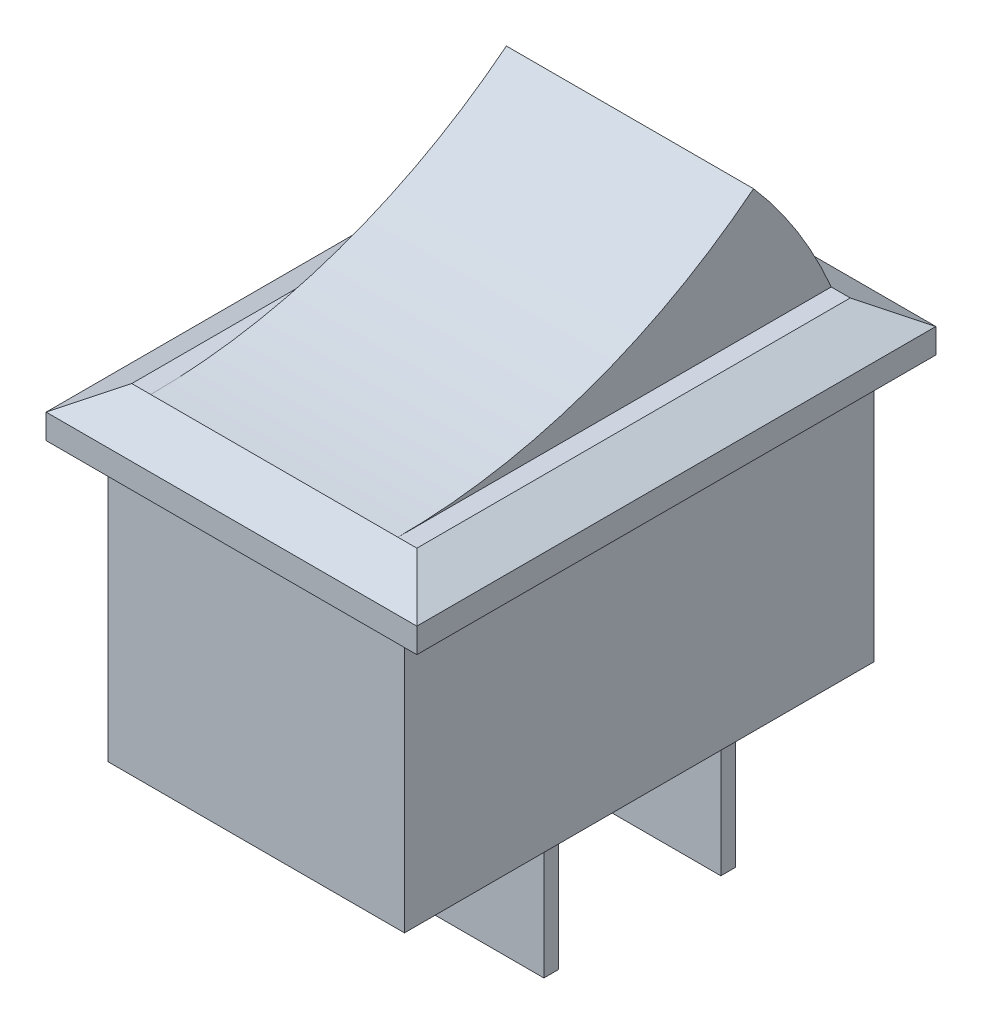
from build123d import *

# Parameters (mm, degrees)
SKETCH1_W             = 12
SKETCH1_H             = 19
BOSS_EXTRUDE1_DEPTH   = 11
SKETCH2_W             = 15
SKETCH2_H             = 21
SKETCH2_W_2           = 10
SKETCH2_H_2           = 16
BOSS_EXTRUDE2_DEPTH   = 2
CHAMFER1_SIZE         = 1
CHAMFER1_SIZE2        = 1.732050808
CHAMFER1_PART_2_SIZE  = 1
CHAMFER1_PART_2_SIZE2 = 1.732050808
CHAMFER1_PART_3_SIZE  = 1
CHAMFER1_PART_3_SIZE2 = 1.732050808
CHAMFER1_PART_4_SIZE  = 1
CHAMFER1_PART_4_SIZE2 = 1.732050808
BOSS_EXTRUDE3_DEPTH   = 10
SKETCH4_W             = 4.8
SKETCH4_H             = 0.6
BOSS_EXTRUDE4_DEPTH   = 8


with BuildPart() as part:
    # Sketch1 → Boss-Extrude1 (new body)
    with BuildSketch(Plane(origin=(0, 0, 0), x_dir=(1, 0, 0), z_dir=(0, 1, 0))):
        Rectangle(SKETCH1_W, SKETCH1_H)
    extrude(amount=BOSS_EXTRUDE1_DEPTH)

    # Sketch2 → Boss-Extrude2 (add)
    with BuildSketch(Plane(origin=(0, 11, 0), x_dir=(1, 0, 0), z_dir=(0, 1, 0))):
        Rectangle(SKETCH2_W, SKETCH2_H)
        Rectangle(SKETCH2_W_2, SKETCH2_H_2, mode=Mode.SUBTRACT)
    extrude(amount=BOSS_EXTRUDE2_DEPTH)

    # Chamfer1
    chamfer1_edges = [part.edges().sort_by_distance(p)[0] for p in [
        (-7.5, 13, 0),
    ]]
    chamfer1_side = [part.faces().sort_by_distance(p)[0] for p in [
        (-7.5, 12, 0),
    ]]
    chamfer(chamfer1_edges, length=CHAMFER1_SIZE, length2=CHAMFER1_SIZE2, reference=chamfer1_side[0])

    # Chamfer1 part 2
    chamfer1_part_2_edges = [part.edges().sort_by_distance(p)[0] for p in [
        (0, 13, 10.5),
    ]]
    chamfer1_part_2_side = [part.faces().sort_by_distance(p)[0] for p in [
        (0, 12, 10.5),
    ]]
    chamfer(chamfer1_part_2_edges, length=CHAMFER1_PART_2_SIZE, length2=CHAMFER1_PART_2_SIZE2, reference=chamfer1_part_2_side[0])

    # Chamfer1 part 3
    chamfer1_part_3_edges = [part.edges().sort_by_distance(p)[0] for p in [
        (7.5, 13, 0),
    ]]
    chamfer1_part_3_side = [part.faces().sort_by_distance(p)[0] for p in [
        (7.5, 12, 0),
    ]]
    chamfer(chamfer1_part_3_edges, length=CHAMFER1_PART_3_SIZE, length2=CHAMFER1_PART_3_SIZE2, reference=chamfer1_part_3_side[0])

    # Chamfer1 part 4
    chamfer1_part_4_edges = [part.edges().sort_by_distance(p)[0] for p in [
        (0, 13, -10.5),
    ]]
    chamfer1_part_4_side = [part.faces().sort_by_distance(p)[0] for p in [
        (0, 12, -10.5),
    ]]
    chamfer(chamfer1_part_4_edges, length=CHAMFER1_PART_4_SIZE, length2=CHAMFER1_PART_4_SIZE2, reference=chamfer1_part_4_side[0])

    # Sketch3 → Boss-Extrude3 (add)
    with BuildSketch(Plane(origin=(-5, 0, 0), x_dir=(0, 0, -1), z_dir=(1, 0, 0))):
        with BuildLine():
            Line((-8.767949192, 13), (-8.767949192, 12))
            Line((-8.767949192, 12), (9.162687499, 12))
            ThreePointArc((9.162687499, 12), (7.670106688, 15.172024144), (5.622167077, 18.017279493))
            ThreePointArc((5.622167077, 18.017279493), (-1.14809782, 14.290285439), (-8.767949192, 13))
        make_face()
    extrude(amount=BOSS_EXTRUDE3_DEPTH)

    # Sketch4 → Boss-Extrude4 (add)
    with BuildSketch(Plane.XZ):
        with Locations((0, -7.2)):
            Rectangle(SKETCH4_W, SKETCH4_H)
        with Locations((0, -0.04)):
            Rectangle(SKETCH4_W, SKETCH4_H)
    extrude(amount=BOSS_EXTRUDE4_DEPTH)


solid = part.part
